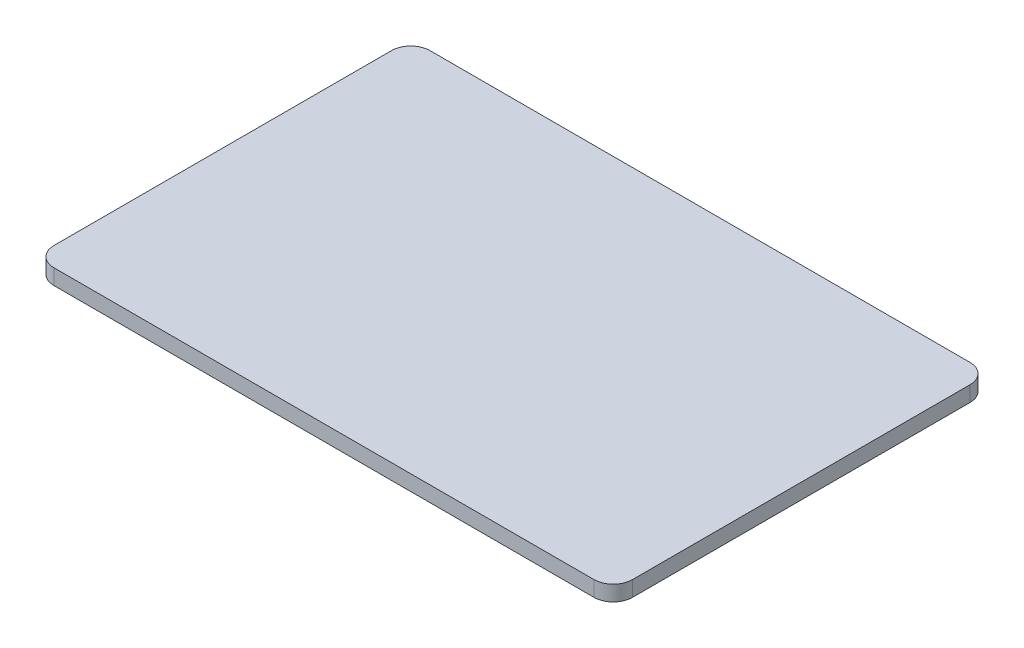
from build123d import *

# Parameters (mm, degrees)
SKETCH1_W           = 40
SKETCH1_H           = 39
BOSS_EXTRUDE1_DEPTH = 1.6
SKETCH2_W           = 20
SKETCH2_H           = 39
BOSS_EXTRUDE2_DEPTH = 1.6
FILLET1_R           = 2


with BuildPart() as part:
    # Sketch1 → Boss-Extrude1 (new body)
    with BuildSketch(Plane(origin=(0, 0, 0), x_dir=(1, 0, 0), z_dir=(0, 1, 0))):
        Rectangle(SKETCH1_W, SKETCH1_H)
    extrude(amount=BOSS_EXTRUDE1_DEPTH)

    # Sketch2 → Boss-Extrude2 (add)
    with BuildSketch(Plane(origin=(0, 0, 0), x_dir=(1, 0, 0), z_dir=(0, 1, 0))):
        with Locations((-30, 0)):
            Rectangle(SKETCH2_W, SKETCH2_H)
    extrude(amount=BOSS_EXTRUDE2_DEPTH)

    # Fillet1
    fillet1_edges = [part.edges().sort_by_distance(p)[0] for p in [
        (-40, 0.8, -19.5),
        (-40, 0.8, 19.5),
        (20, 0.8, -19.5),
        (20, 0.8, 19.5),
    ]]
    fillet(fillet1_edges, radius=FILLET1_R)


solid = part.part
